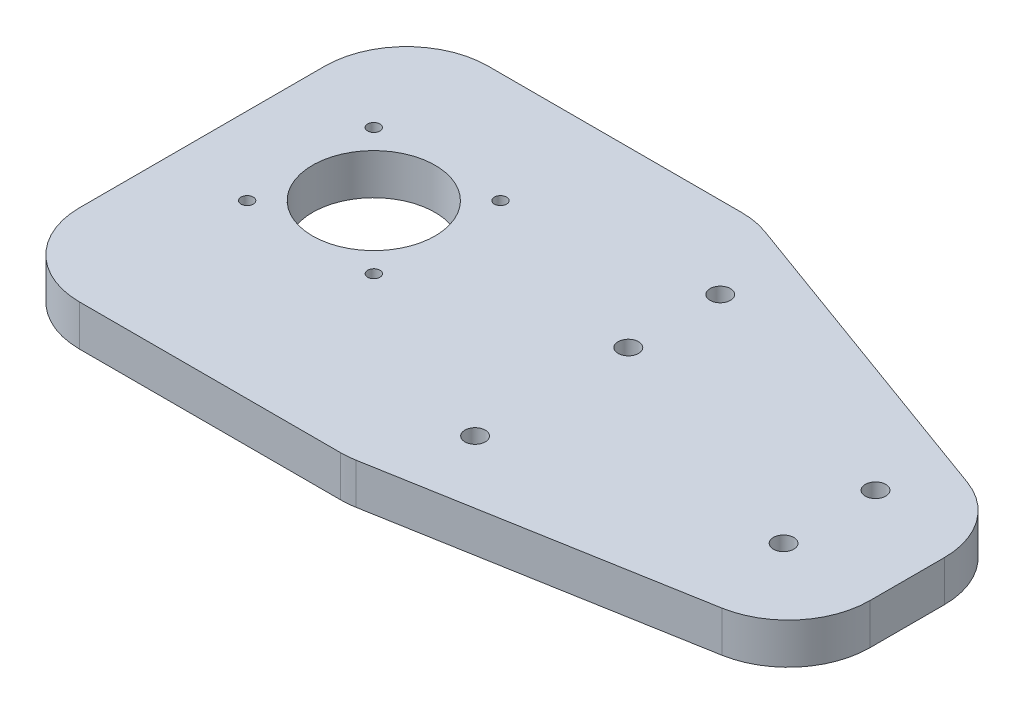
from build123d import *

# Parameters (mm, degrees)
SKETCH2_R           = 2.5
SKETCH2_R_2         = 15
SKETCH2_R_3         = 1.5
BOSS_EXTRUDE1_DEPTH = 10


with BuildPart() as part:
    # Sketch2 → Boss-Extrude1 (new body)
    with BuildSketch(Plane(origin=(0, 0, 0), x_dir=(1, 0, 0), z_dir=(0, 1, 0))):
        with BuildLine():
            Line((0, 20), (0, 80))
            ThreePointArc((0, 80), (5.857864376, 94.142135624), (20, 100))
            Line((20, 100), (82.080969389, 100))
            ThreePointArc((82.080969389, 100), (85.553932943, 99.69615506), (88.921372256, 98.793852416))
            Line((88.921372256, 98.793852416), (166.840402867, 70.433644591))
            ThreePointArc((166.840402867, 70.433644591), (176.383040886, 63.111320902), (180, 51.639792175))
            Line((180, 51.639792175), (180, 33.425935563))
            ThreePointArc((180, 33.425935563), (175.320888862, 20.570183369), (163.472963553, 13.729780502))
            Line((163.472963553, 13.729780502), (87.330699286, 0.30384494))
            ThreePointArc((87.330699286, 0.30384494), (85.600850588, 0.076106038), (83.857735733, 0))
            Line((83.857735733, 0), (20, 0))
            ThreePointArc((20, 0), (5.857864376, 5.857864376), (0, 20))
        make_face()
        with Locations((96.8, 80)):
            Circle(SKETCH2_R, mode=Mode.SUBTRACT)
        with Locations((96.8, 20)):
            Circle(SKETCH2_R, mode=Mode.SUBTRACT)
        with Locations((157.3, 35)):
            Circle(SKETCH2_R, mode=Mode.SUBTRACT)
        with Locations((34.5, 57.5)):
            Circle(SKETCH2_R_2, mode=Mode.SUBTRACT)
        with Locations((19, 73)):
            Circle(SKETCH2_R_3, mode=Mode.SUBTRACT)
        with Locations((50, 73)):
            Circle(SKETCH2_R_3, mode=Mode.SUBTRACT)
        with Locations((19, 42)):
            Circle(SKETCH2_R_3, mode=Mode.SUBTRACT)
        with Locations((50, 42)):
            Circle(SKETCH2_R_3, mode=Mode.SUBTRACT)
        with Locations((96.8, 57.5)):
            Circle(SKETCH2_R, mode=Mode.SUBTRACT)
        with Locations((157.3, 57.5)):
            Circle(SKETCH2_R, mode=Mode.SUBTRACT)
    extrude(amount=BOSS_EXTRUDE1_DEPTH)


solid = part.part
